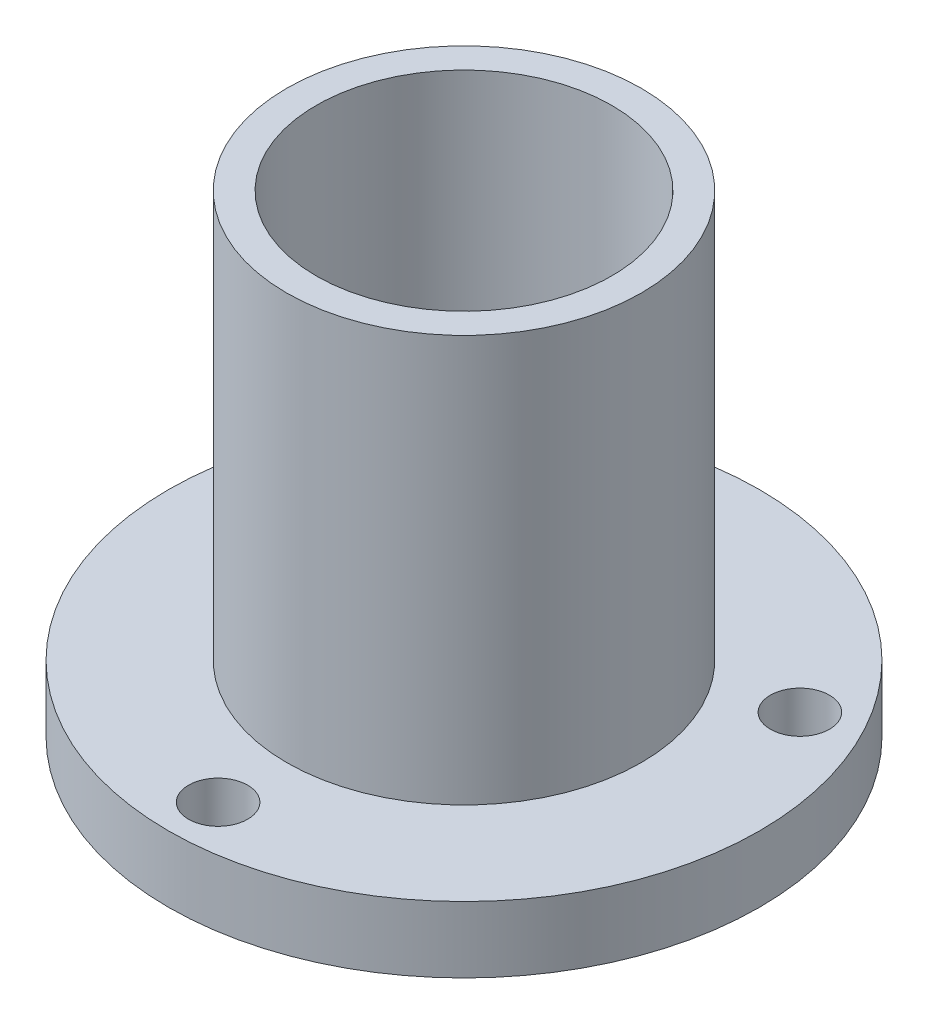
from build123d import *

# Parameters (mm, degrees)
SKETCH1_R               = 7.9375
BOSS_EXTRUDE1_DEPTH     = 1.778
SKETCH2_R               = 4.7625
BOSS_EXTRUDE2_DEPTH     = 10.922
SKETCH4_R               = 3.96875
CUT_EXTRUDE3_DEPTH      = 1
CUT_EXTRUDE3_DEPTH_BACK = 13.7
SKETCH7_R               = 0.79375
CUT_EXTRUDE5_DEPTH      = 13.7


with BuildPart() as part:
    # Sketch1 → Boss-Extrude1 (new body)
    with BuildSketch(Plane(origin=(0, 0, 0), x_dir=(1, 0, 0), z_dir=(0, 1, 0))):
        Circle(SKETCH1_R)
    extrude(amount=BOSS_EXTRUDE1_DEPTH)

    # Sketch2 → Boss-Extrude2 (add)
    with BuildSketch(Plane(origin=(0, 1.778, 0), x_dir=(1, 0, 0), z_dir=(0, 1, 0))):
        Circle(SKETCH2_R)
    extrude(amount=BOSS_EXTRUDE2_DEPTH)

    # Sketch4 → Cut-Extrude3 (cut, two sides)
    with BuildSketch(Plane.XZ) as cut_extrude3_sk:
        Circle(SKETCH4_R)
    extrude(amount=CUT_EXTRUDE3_DEPTH, mode=Mode.SUBTRACT)
    extrude(cut_extrude3_sk.sketch, amount=-CUT_EXTRUDE3_DEPTH_BACK, mode=Mode.SUBTRACT)

    # Sketch7 → Cut-Extrude5 (cut, through all)
    with BuildSketch(Plane.XZ):
        with Locations((0, 6.604)):
            Circle(SKETCH7_R)
        with Locations((5.719231767, -3.302)):
            Circle(SKETCH7_R)
        with Locations((-5.719231767, -3.302)):
            Circle(SKETCH7_R)
    extrude(amount=-CUT_EXTRUDE5_DEPTH, mode=Mode.SUBTRACT)


solid = part.part
